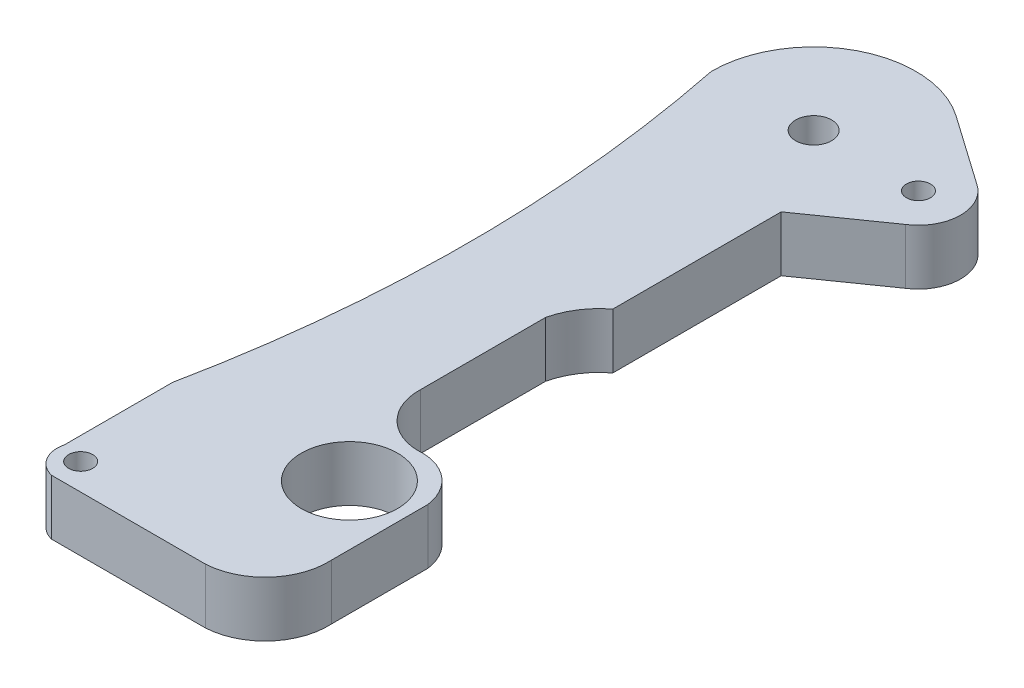
from build123d import *

# Parameters (mm, degrees)
SKETCH1_R           = 1.5
SKETCH1_R_2         = 1
SKETCH1_R_3         = 4
BOSS_EXTRUDE1_DEPTH = 4.6


with BuildPart() as part:
    # Sketch1 → Boss-Extrude1 (new body)
    with BuildSketch(Plane(origin=(0, 0, 0), x_dir=(1, 0, 0), z_dir=(0, 1, 0))):
        with BuildLine():
            Line((33.841256749, 14.73946958), (36.132184269, 14.73946958))
            ThreePointArc((36.132184269, 14.73946958), (39.75713684, 16.478313044), (41.09081738, 20.271089593))
            Line((41.09081738, 20.271089593), (41.09081738, 28.286294101))
            ThreePointArc((41.09081738, 28.286294101), (39.602380799, 30.901377208), (36.712338736, 31.739088372))
            ThreePointArc((36.712338736, 31.739088372), (33.680921675, 33.128286782), (32.51969773, 36.254133959))
            Line((32.51969773, 36.254133959), (32.51969773, 46.640032758))
            ThreePointArc((32.51969773, 46.640032758), (33.320707465, 48.524930167), (34.713196388, 50.026738889))
            Line((34.713196388, 50.026738889), (34.713196388, 64.026738889))
            Line((34.713196388, 64.026738889), (40.7852702, 68.285935139))
            ThreePointArc((40.7852702, 68.285935139), (42.40733668, 71.23946958), (40.7852702, 74.193004021))
            Line((40.7852702, 74.193004021), (35.075266798, 78.198229556))
            ThreePointArc((35.075266798, 78.198229556), (26.272366536, 78.780683171), (21.694113287, 71.23946958))
            ThreePointArc((21.694113287, 71.23946958), (23.941923331, 48.851382594), (21.694113287, 26.463295609))
            Line((21.694113287, 26.463295609), (21.694113287, 17.463295609))
            ThreePointArc((21.694113287, 17.463295609), (21.954167675, 15.759997208), (23.342467746, 14.73946958))
            Line((23.342467746, 14.73946958), (33.841256749, 14.73946958))
        make_face()
        with Locations((30.194113287, 71.23946958)):
            Circle(SKETCH1_R, mode=Mode.SUBTRACT)
        with Locations((38.90733668, 71.23946958)):
            Circle(SKETCH1_R_2, mode=Mode.SUBTRACT)
        with Locations((23.566412567, 16.94349474)):
            Circle(SKETCH1_R_2, mode=Mode.SUBTRACT)
        with Locations((36.132184269, 26.716174154)):
            Circle(SKETCH1_R_3, mode=Mode.SUBTRACT)
    extrude(amount=BOSS_EXTRUDE1_DEPTH)


solid = part.part
